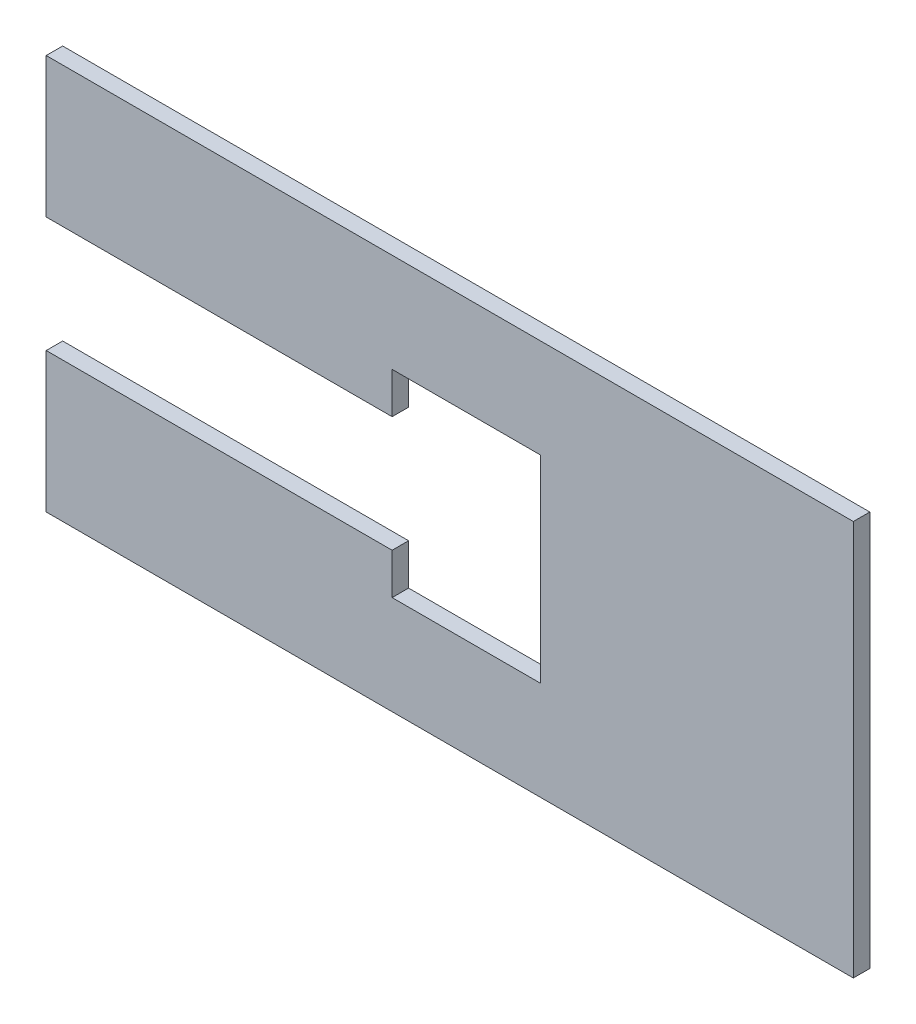
from build123d import *

# Parameters (mm, degrees)
ESQUISSE1_W             = 245
ESQUISSE1_H             = 120
BOSS_EXTRU_1_DEPTH      = 5
ENL_V_MAT_EXTRU_1_DEPTH = 6


with BuildPart() as part:
    # Esquisse1 → Boss.-Extru.1 (new body)
    with BuildSketch(Plane.XY):
        Rectangle(ESQUISSE1_W, ESQUISSE1_H)
    extrude(amount=BOSS_EXTRU_1_DEPTH)

    # Esquisse2 → Enlèv. mat.-Extru.1 (cut, through all)
    with BuildSketch(Plane.XY.offset(5)):
        Polygon((-122.5, 17.55), (-17.5, 17.55), (-17.5, 30), (27.5, 30), (27.5, -30), (-17.5, -30), (-17.5, -17.55), (-122.5, -17.55), align=None)
    extrude(amount=-ENL_V_MAT_EXTRU_1_DEPTH, mode=Mode.SUBTRACT)


solid = part.part
